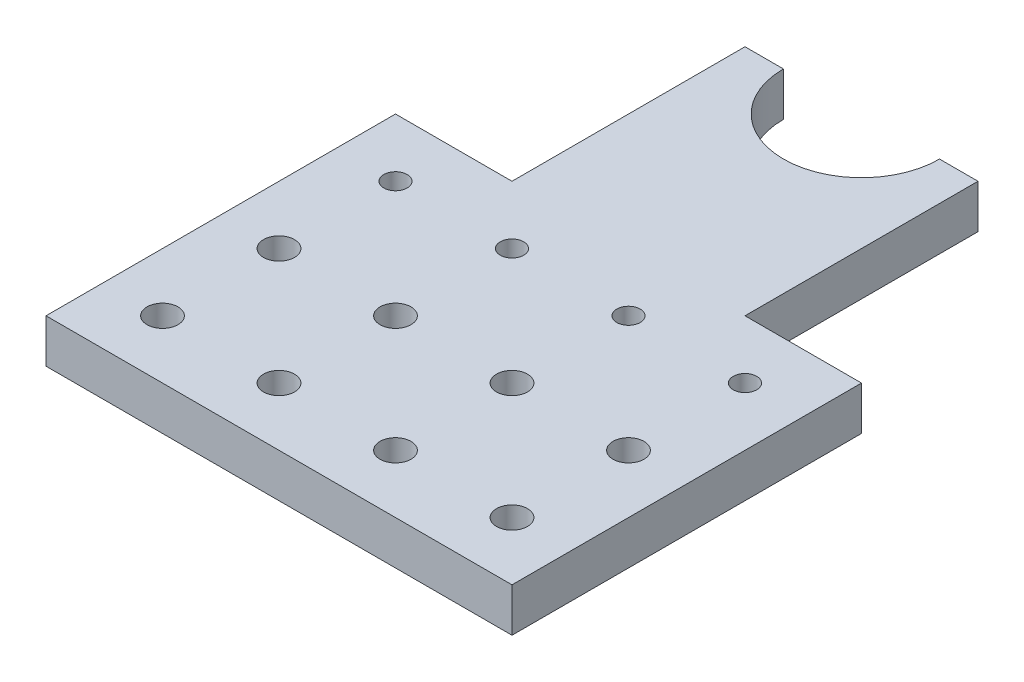
from build123d import *

# Parameters (mm, degrees)
SKETCH1_W                   = 101.6
SKETCH1_H                   = 127
BOSS_EXTRUDE1_DEPTH         = 9.525
SKETCH2_R                   = 17.018
CUT_EXTRUDE1_DEPTH          = 10.525
F_1_4_CLEARANCE_HOLE1_D     = 6.7564
LPATTERN1_COUNT             = 2
LPATTERN1_PITCH             = 25.4
LPATTERN1_COUNT_DIR2        = 4
LPATTERN1_PITCH_DIR2        = 25.4
TAP_DRILL_FOR_1_4_20_TAP1_D = 5.1054
LPATTERN2_COUNT             = 4
LPATTERN2_PITCH             = 25.4
SKETCH7_W                   = 25.4
SKETCH7_H                   = 50.8
CUT_EXTRUDE2_DEPTH          = 10.525
LPATTERN3_COUNT             = 2
LPATTERN3_PITCH             = 42.291


with BuildPart() as part:
    # Sketch1 → Boss-Extrude1 (new body)
    with BuildSketch(Plane(origin=(0, 0, 0), x_dir=(1, 0, 0), z_dir=(0, 1, 0))):
        with Locations((50.8, 63.5)):
            Rectangle(SKETCH1_W, SKETCH1_H)
    extrude(amount=BOSS_EXTRUDE1_DEPTH)

    # Sketch2 → Cut-Extrude1 (cut, through all)
    with BuildSketch(Plane(origin=(0, 9.525, 0), x_dir=(1, 0, 0), z_dir=(0, 1, 0))):
        with Locations((50.8, 127)):
            Circle(SKETCH2_R)
    extrude(amount=-CUT_EXTRUDE1_DEPTH, mode=Mode.SUBTRACT)

    # 1/4 Clearance Hole1 (through all)
    with Locations(Plane(origin=(0, 9.525, 0), x_dir=(-1, 0, 0), z_dir=(0, 1, 0))):
        with Locations((-12.7, -12.7)):
            f_1_4_clearance_hole1 = Hole(F_1_4_CLEARANCE_HOLE1_D / 2)

    # LPattern1: 1_4 Clearance Hole1 2 × 4
    with Locations(*[(j * LPATTERN1_PITCH_DIR2, 0, -i * LPATTERN1_PITCH) for i in range(LPATTERN1_COUNT) for j in range(LPATTERN1_COUNT_DIR2) if (i, j) != (0, 0)]):
        add(f_1_4_clearance_hole1, mode=Mode.SUBTRACT)

    # Tap Drill for 1/4-20 Tap1 (through all)
    with Locations(Plane(origin=(0, 9.525, 0), x_dir=(-1, 0, 0), z_dir=(0, 1, 0))):
        with Locations((-12.7, -63.5)):
            tap_drill_for_1_4_20_tap1 = Hole(TAP_DRILL_FOR_1_4_20_TAP1_D / 2)

    # LPattern2: Tap Drill for 1/4-20 Tap1 ×4
    with Locations(*[(i * LPATTERN2_PITCH, 0, 0) for i in range(1, LPATTERN2_COUNT)]):
        add(tap_drill_for_1_4_20_tap1, mode=Mode.SUBTRACT)

    # Sketch7 → Cut-Extrude2 (cut, through all)
    with BuildSketch(Plane(origin=(0, 9.525, 0), x_dir=(1, 0, 0), z_dir=(0, 1, 0))):
        with Locations((12.7, 101.6)):
            Rectangle(SKETCH7_W, SKETCH7_H)
        with Locations((88.9, 101.6)):
            Rectangle(SKETCH7_W, SKETCH7_H)
    extrude(amount=-CUT_EXTRUDE2_DEPTH, mode=Mode.SUBTRACT)

    # Sketch8 → #8-32 Tapped Hole1 (revolve, cut)
    with BuildSketch(Plane(origin=(29.6545, 4.7625, -127), x_dir=(0, 1, 0), z_dir=(1, 0, 0))):
        Polygon((0, 0), (0, 11.705806461), (1.7272, 10.668), (1.7272, 0), align=None)
    f_8_32_tapped_hole1 = revolve(axis=Axis((29.6545, 4.7625, -133.35), (0, 0, 1)), mode=Mode.SUBTRACT)

    # LPattern3: #8-32 Tapped Hole1 ×2
    with Locations(*[(i * LPATTERN3_PITCH, 0, 0) for i in range(1, LPATTERN3_COUNT)]):
        add(f_8_32_tapped_hole1, mode=Mode.SUBTRACT)


solid = part.part
